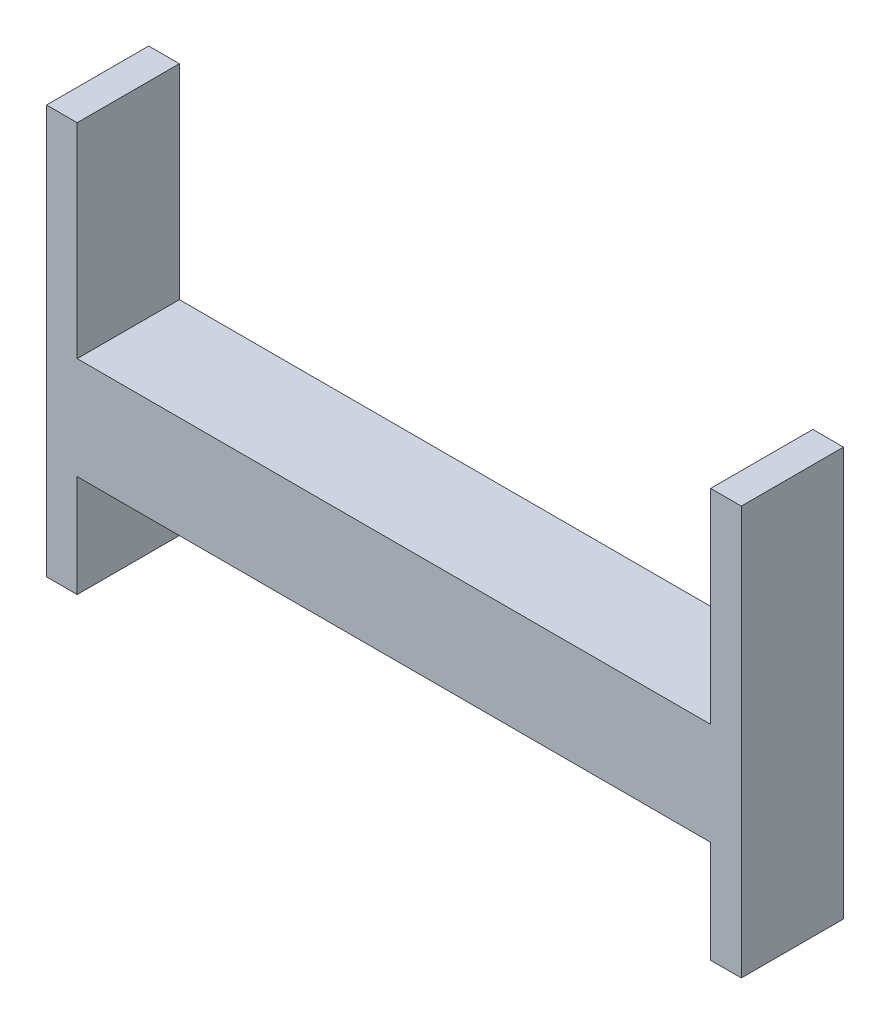
from build123d import *

# Parameters (mm, degrees)
SALIENTE_EXTRUIR3_DEPTH = 50


with BuildPart() as part:
    # Croquis1 → Saliente-Extruir3 (new body)
    with BuildSketch(Plane.XY):
        Polygon((155, -25), (-155, -25), (-155, -75), (-170, -75), (-170, -25), (-170, 125), (-155, 125), (-155, 25), (155, 25), (155, 125), (170, 125), (170, -25), (170, -75), (155, -75), align=None)
    extrude(amount=SALIENTE_EXTRUIR3_DEPTH)


solid = part.part
